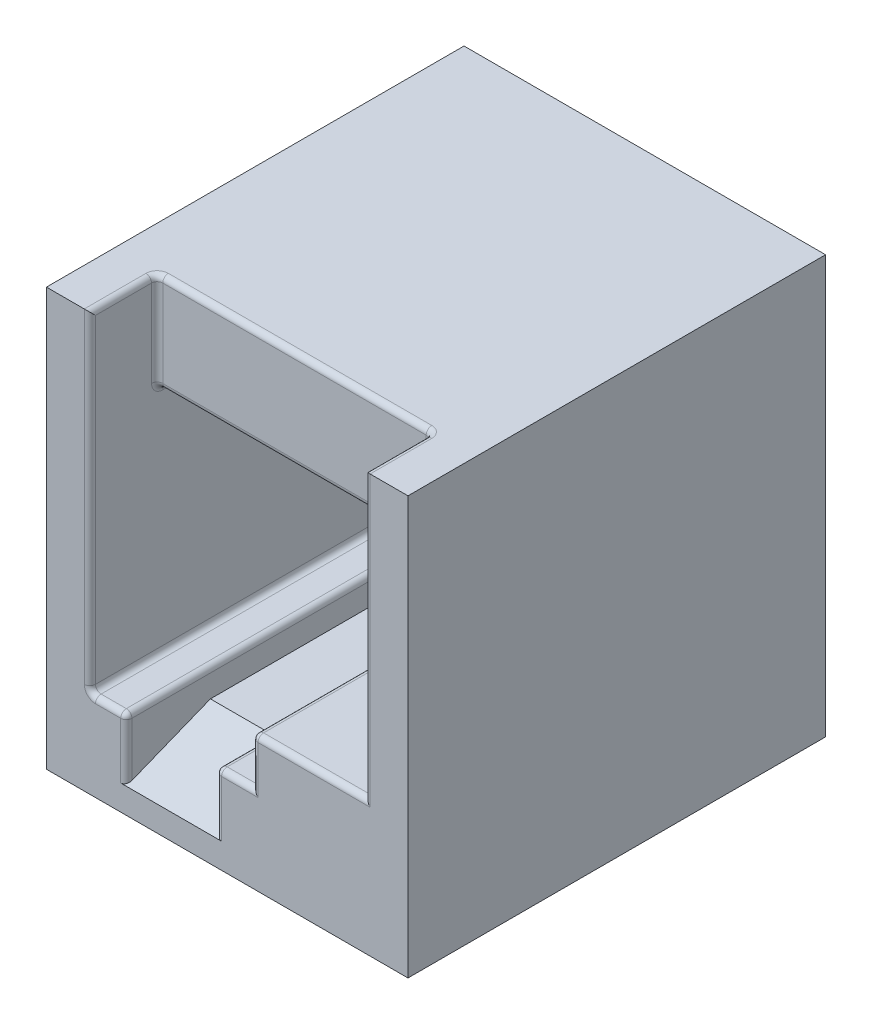
from build123d import *

# Parameters (mm, degrees)
SKETCH1_W      = 12.9
SKETCH1_H      = 14.9
EXTRUDE1_DEPTH = 14.9
SKETCH2_W      = 9.8
SKETCH2_H      = 3.5
EXTRUDE2_DEPTH = 2.4
EXTRUDE3_DEPTH = 12.5
CHAMFER1_SIZE  = 1.2
CHAMFER1_SIZE2 = 3
FILLET1_R      = 0.2


with BuildPart() as part:
    # Sketch1 → Extrude1 (new body)
    with BuildSketch(Plane.XY):
        with Locations((6.45, 7.45)):
            Rectangle(SKETCH1_W, SKETCH1_H)
    extrude(amount=-EXTRUDE1_DEPTH)

    # Sketch2 → Extrude2 (cut)
    with BuildSketch(Plane.XY):
        with Locations((6.45, 13.15)):
            Rectangle(SKETCH2_W, SKETCH2_H)
    extrude(amount=-EXTRUDE2_DEPTH, mode=Mode.SUBTRACT)

    # Sketch3 → Extrude3 (cut)
    with BuildSketch(Plane.XY):
        Polygon((1.55, 11.4), (1.55, 3.1), (2.85, 3.1), (2.85, 2.1), (6.05, 2.1), (6.05, 3.1), (7.35, 3.1), (7.35, 4.8), (11.35, 4.8), (11.35, 11.4), align=None)
    extrude(amount=-EXTRUDE3_DEPTH, mode=Mode.SUBTRACT)

    # Chamfer1
    chamfer1_edges = [part.edges().sort_by_distance(p)[0] for p in [
        (4.45, 2.1, 0),
    ]]
    chamfer1_side = [part.faces().sort_by_distance(p)[0] for p in [
        (0.775, 14.702916261, 0),
    ]]
    chamfer(chamfer1_edges, length=CHAMFER1_SIZE, length2=CHAMFER1_SIZE2, reference=chamfer1_side[0])

    # Fillet1
    fillet1_edges = [part.edges().sort_by_distance(p)[0] for p in [
        (1.55, 13.15, -2.4),
        (6.45, 14.9, -2.4),
        (1.55, 14.9, -1.2),
        (11.35, 13.15, -2.4),
        (11.35, 14.9, -1.2),
        (6.45, 11.4, -2.4),
        (1.55, 9, 0),
        (11.35, 9.85, 0),
        (6.45, 11.4, -12.5),
        (1.55, 11.4, -7.45),
        (11.35, 8.1, -12.5),
        (11.35, 11.4, -7.45),
        (9.35, 4.8, -12.5),
        (7.35, 3.95, -12.5),
        (7.35, 4.8, -6.25),
        (6.7, 3.1, -12.5),
        (6.05, 2.6, -12.5),
        (6.05, 3.1, -6.25),
        (2.85, 2.6, -12.5),
        (2.2, 3.1, -12.5),
        (2.85, 3.1, -6.25),
        (1.55, 7.25, -12.5),
        (1.55, 3.1, -6.25),
        (2.2, 3.1, 0),
        (2.85, 1.5, 0),
        (6.05, 1.5, 0),
        (6.7, 3.1, 0),
        (7.35, 3.95, 0),
        (9.35, 4.8, 0),
    ]]
    fillet(fillet1_edges, radius=FILLET1_R)


solid = part.part
